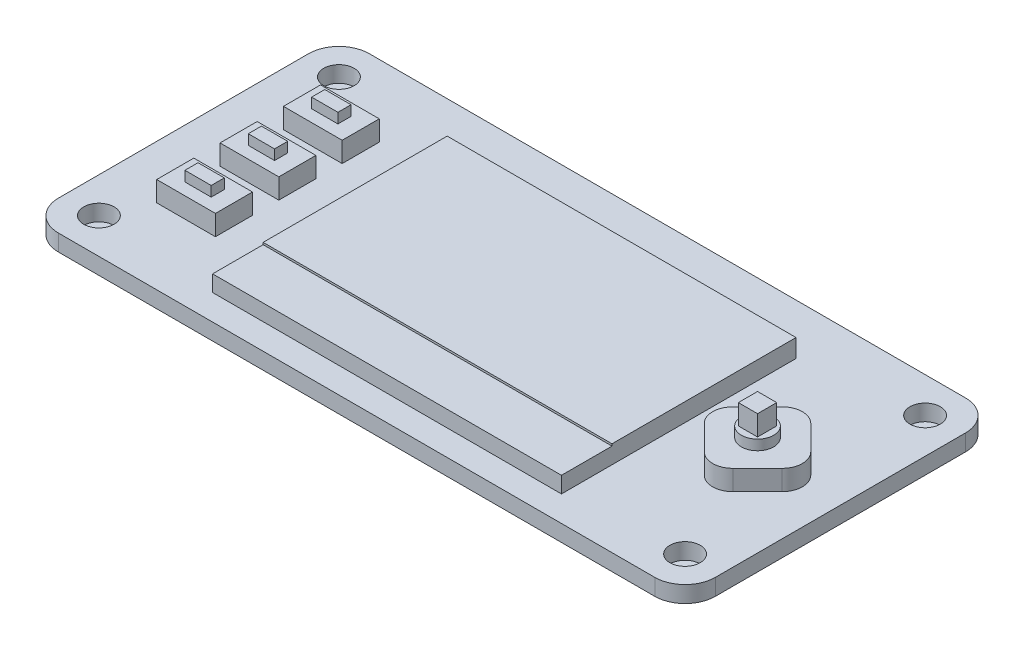
from build123d import *

# Parameters (mm, degrees)
EXTRUDE_1_DEPTH     = 1.63
SKETCH_2_R          = 1.5
CUT_EXTRUDE_1_DEPTH = 1.6
SKETCH_3_W          = 34.52
SKETCH_3_H          = 23.21
EXTRUDE_2_DEPTH     = 1.8
EXTRUDE_3_DEPTH     = 2
SKETCH_4_W          = 5.81
SKETCH_4_H          = 3.67
EXTRUDE_4_DEPTH     = 2
SKETCH_7_W          = 2.6
SKETCH_7_H          = 1.3
EXTRUDE_5_DEPTH     = 1
SKETCH_8_W          = 51
SKETCH_8_H          = 5
EXTRUDE_6_DEPTH     = 3.68
SKETCH_9_W          = 1.9
SKETCH_9_H          = 1.9
EXTRUDE_7_DEPTH     = 3
SKETCH_10_R         = 1.6
EXTRUDE_8_DEPTH     = 1
SKETCH_11_W         = 34.52
SKETCH_11_H         = 5
CUT_EXTRUDE_2_DEPTH = 0.2


with BuildPart() as part:
    # 草图1 → 凸台-拉伸1 (new body)
    with BuildSketch(Plane(origin=(0, 0, 0), x_dir=(1, 0, 0), z_dir=(0, 1, 0))):
        with BuildLine():
            Line((-29.5, 15.375), (29.5, 15.375))
            ThreePointArc((29.5, 15.375), (31.621320344, 14.496320344), (32.5, 12.375))
            Line((32.5, 12.375), (32.5, -12.375))
            ThreePointArc((32.5, -12.375), (31.621320344, -14.496320344), (29.5, -15.375))
            Line((29.5, -15.375), (-29.5, -15.375))
            ThreePointArc((-29.5, -15.375), (-31.621320344, -14.496320344), (-32.5, -12.375))
            Line((-32.5, -12.375), (-32.5, 12.375))
            ThreePointArc((-32.5, 12.375), (-31.621320344, 14.496320344), (-29.5, 15.375))
        make_face()
    extrude(amount=EXTRUDE_1_DEPTH)

    # 草图2 → 切除-拉伸1 (cut)
    with BuildSketch(Plane(origin=(0, 1.63, 0), x_dir=(1, 0, 0), z_dir=(0, 1, 0))):
        with Locations(Location((-29, 11.875, 0), (0, 0, 270))):  # turned: the seam where the file's is
            Circle(SKETCH_2_R)
        with Locations(Location((-29, -11.875, 0), (0, 0, 270))):  # turned: the seam where the file's is
            Circle(SKETCH_2_R)
        with Locations(Location((29, -11.875, 0), (0, 0, 270))):  # turned: the seam where the file's is
            Circle(SKETCH_2_R)
        with Locations(Location((29, 11.875, 0), (0, 0, 270))):  # turned: the seam where the file's is
            Circle(SKETCH_2_R)
    extrude(amount=-CUT_EXTRUDE_1_DEPTH, mode=Mode.SUBTRACT)

    # 草图3 → 凸台-拉伸2 (add)
    with BuildSketch(Plane(origin=(0, 1.63, 0), x_dir=(1, 0, 0), z_dir=(0, 1, 0))):
        with Locations((0.48, -1.24)):
            Rectangle(SKETCH_3_W, SKETCH_3_H)
    extrude(amount=EXTRUDE_2_DEPTH)

    # 草图5 → 凸台-拉伸3 (add)
    with BuildSketch(Plane(origin=(0, 1.63, 0), x_dir=(1, 0, 0), z_dir=(0, 1, 0))):
        with BuildLine():
            Line((26.024695167, 3.538250353), (28.464213562, 1.098731957))
            ThreePointArc((28.464213562, 1.098731957), (29.05, -0.315481605), (28.464213562, -1.729695167))
            Line((28.464213562, -1.729695167), (26.024695167, -4.169213562))
            ThreePointArc((26.024695167, -4.169213562), (24.610481605, -4.755), (23.196268043, -4.169213562))
            Line((23.196268043, -4.169213562), (20.756749647, -1.729695167))
            ThreePointArc((20.756749647, -1.729695167), (20.17096321, -0.315481605), (20.756749647, 1.098731957))
            Line((20.756749647, 1.098731957), (23.196268043, 3.538250353))
            ThreePointArc((23.196268043, 3.538250353), (24.610481605, 4.12403679), (26.024695167, 3.538250353))
        make_face()
    extrude(amount=EXTRUDE_3_DEPTH)

    # 草图4 → 凸台-拉伸4 (add)
    with BuildSketch(Plane(origin=(0, 1.63, 0), x_dir=(1, 0, 0), z_dir=(0, 1, 0))):
        with Locations((-24.325, 6.45)):
            Rectangle(SKETCH_4_W, SKETCH_4_H)
        with Locations((-24.325, 0.18)):
            Rectangle(SKETCH_4_W, SKETCH_4_H)
        with Locations((-24.325, -6.09)):
            Rectangle(SKETCH_4_W, SKETCH_4_H)
    extrude(amount=EXTRUDE_4_DEPTH)

    # 草图7 → 凸台-拉伸5 (add)
    with BuildSketch(Plane(origin=(0, 3.63, 0), x_dir=(1, 0, 0), z_dir=(0, 1, 0))):
        with Locations((-24.325, 6.45)):
            Rectangle(SKETCH_7_W, SKETCH_7_H)
        with Locations((-24.325, 0.18)):
            Rectangle(SKETCH_7_W, SKETCH_7_H)
        with Locations((-24.325, -6.09)):
            Rectangle(SKETCH_7_W, SKETCH_7_H)
    extrude(amount=EXTRUDE_5_DEPTH)

    # 草图8 → 凸台-拉伸6 (add)
    with BuildSketch(Plane.XZ):
        with Locations((-0.2, -11.235)):
            Rectangle(SKETCH_8_W, SKETCH_8_H)
    extrude(amount=EXTRUDE_6_DEPTH)

    # 草图9 → 凸台-拉伸7 (add)
    with BuildSketch(Plane(origin=(0, 3.63, 0), x_dir=(1, 0, 0), z_dir=(0, 1, 0))):
        with Locations((24.610481605, -0.315481605)):
            Rectangle(SKETCH_9_W, SKETCH_9_H)
    extrude(amount=EXTRUDE_7_DEPTH)

    # 草图10 → 凸台-拉伸8 (add)
    with BuildSketch(Plane(origin=(0, 3.63, 0), x_dir=(1, 0, 0), z_dir=(0, 1, 0))):
        with Locations(Location((24.610481605, -0.315481605, 0), (0, 0, 90))):  # turned: the seam where the file's is
            Circle(SKETCH_10_R)
    extrude(amount=EXTRUDE_8_DEPTH)

    # 草图11 → 切除-拉伸2 (cut)
    with BuildSketch(Plane(origin=(0, 3.43, 0), x_dir=(1, 0, 0), z_dir=(0, 1, 0))):
        with Locations((0.48, -10.345)):
            Rectangle(SKETCH_11_W, SKETCH_11_H)
    extrude(amount=-CUT_EXTRUDE_2_DEPTH, mode=Mode.SUBTRACT)


solid = part.part
